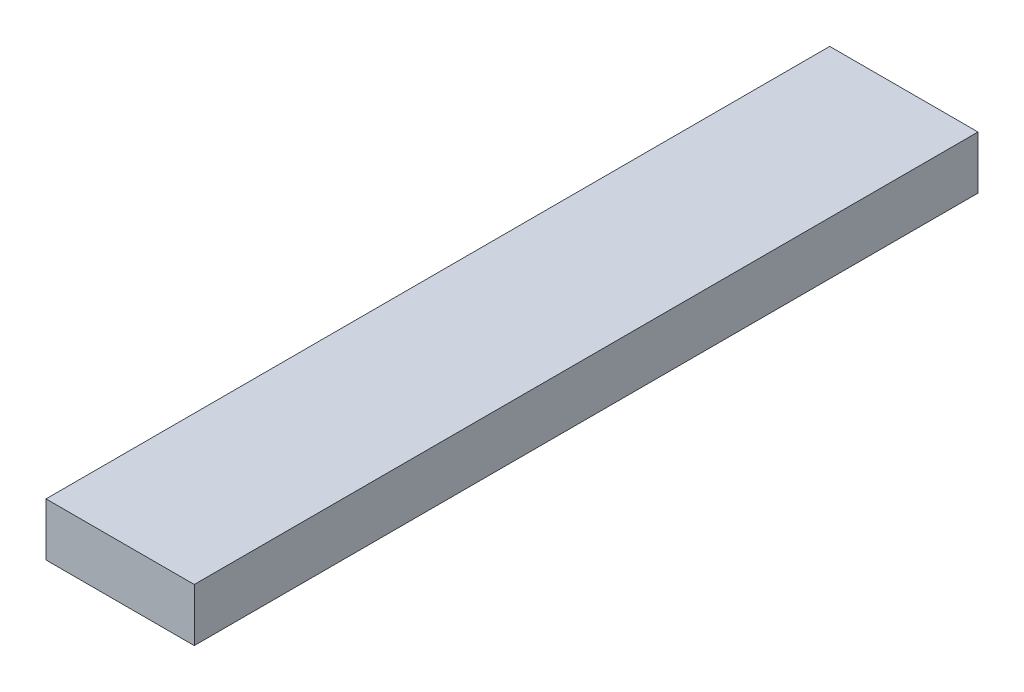
from build123d import *

# Parameters (mm, degrees)
SKETCH1_W           = 14
SKETCH1_H           = 74
BOSS_EXTRUDE1_DEPTH = 5


with BuildPart() as part:
    # Sketch1 → Boss-Extrude1 (new body)
    with BuildSketch(Plane(origin=(0, 0, 0), x_dir=(1, 0, 0), z_dir=(0, 1, 0))):
        with Locations((7, 37)):
            Rectangle(SKETCH1_W, SKETCH1_H)
    extrude(amount=BOSS_EXTRUDE1_DEPTH)


solid = part.part
